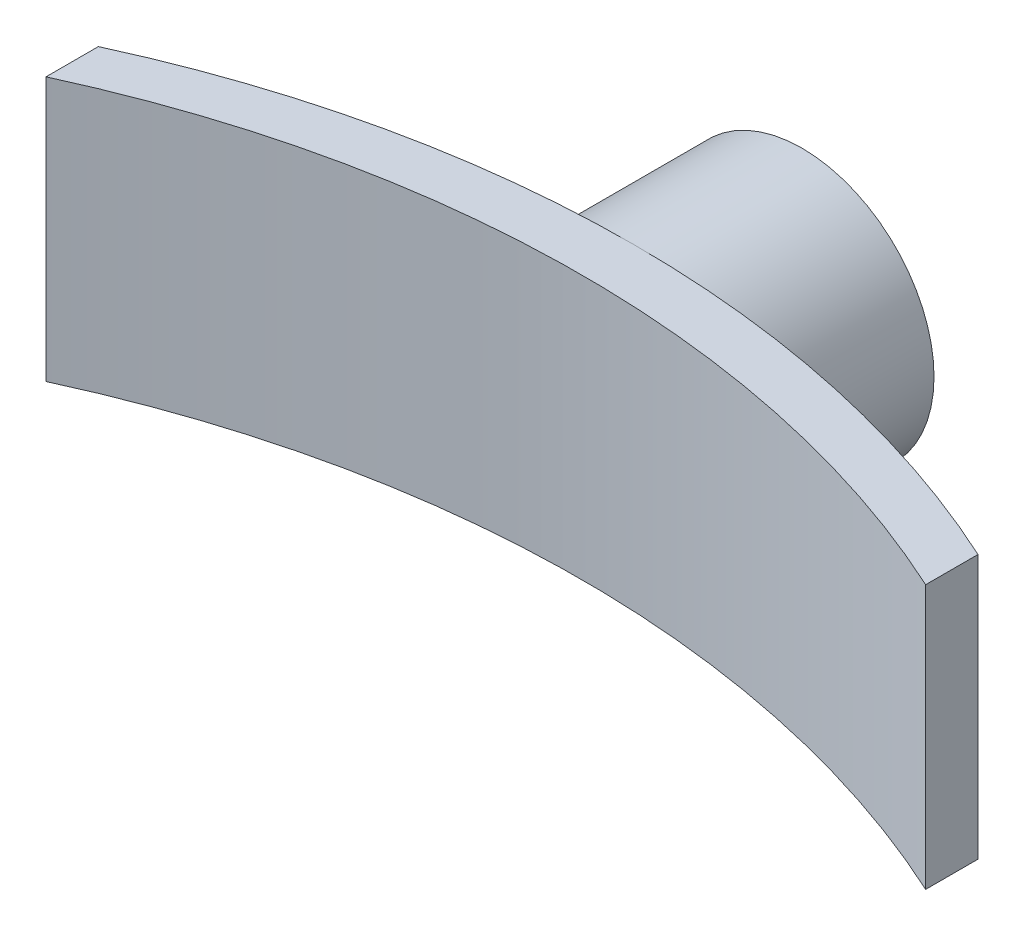
from build123d import *

# Parameters (mm, degrees)
SKETCH1_R                = 15
SKETCH1_R_2              = 2.55
BOSS_EXTRUDE1_DEPTH      = 20
BOSS_EXTRUDE2_DEPTH      = 15
BOSS_EXTRUDE2_DEPTH_BACK = 15


with BuildPart() as part:
    # Sketch1 → Boss-Extrude1 (new body)
    with BuildSketch(Plane.XY):
        Circle(SKETCH1_R)
        Circle(SKETCH1_R_2, mode=Mode.SUBTRACT)
    extrude(amount=BOSS_EXTRUDE1_DEPTH)

    # Sketch2 → Boss-Extrude2 (add, two sides)
    with BuildSketch(Plane(origin=(0, 0, 0), x_dir=(1, 0, 0), z_dir=(0, 1, 0))) as boss_extrude2_sk:
        with BuildLine():
            Line((50, -35.949524979), (50, -30))
            ThreePointArc((50, -30), (0, -19.050475021), (-50, -30))
            Line((-50, -30), (-50, -35.949524979))
            ThreePointArc((-50, -35.949524979), (0, -25), (50, -35.949524979))
        make_face()
    extrude(amount=BOSS_EXTRUDE2_DEPTH)
    extrude(boss_extrude2_sk.sketch, amount=-BOSS_EXTRUDE2_DEPTH_BACK)


solid = part.part
